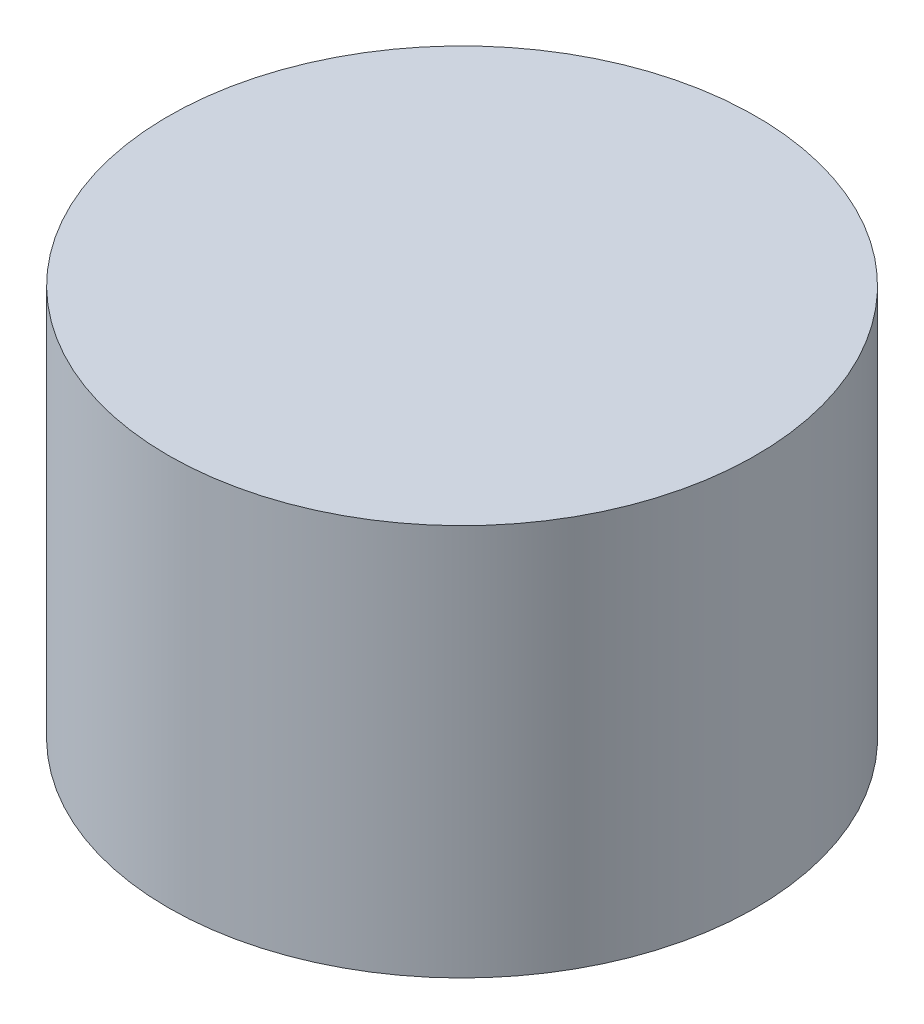
from build123d import *

# Parameters (mm, degrees)
SKETCH1_R           = 7.5
BOSS_EXTRUDE1_DEPTH = 10


with BuildPart() as part:
    # Sketch1 → Boss-Extrude1 (new body)
    with BuildSketch(Plane(origin=(0, 0, 0), x_dir=(1, 0, 0), z_dir=(0, 1, 0))):
        Circle(SKETCH1_R)
    extrude(amount=BOSS_EXTRUDE1_DEPTH)


solid = part.part
